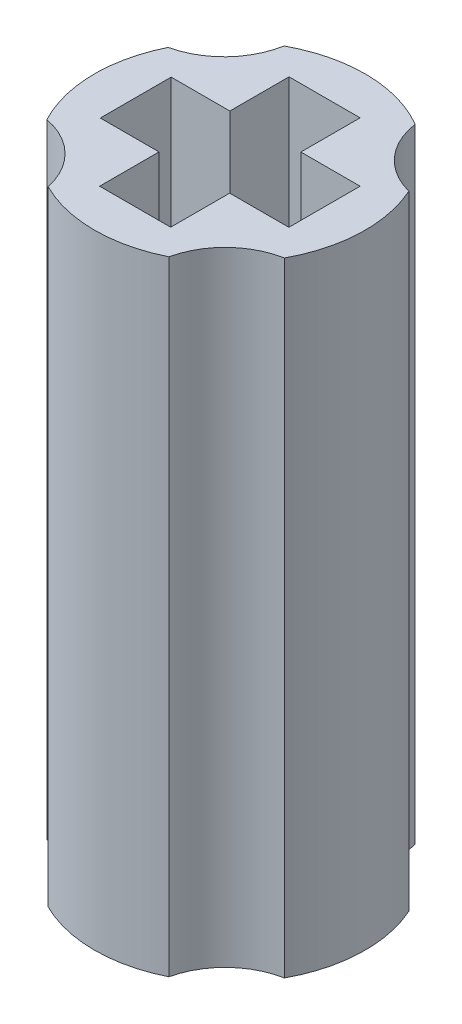
from build123d import *

# Parameters (mm, degrees)
BOSS_EXTRUDE1_DEPTH = 15.8


with BuildPart() as part:
    # Sketch1 → Boss-Extrude1 (new body)
    with BuildSketch(Plane(origin=(0, 0, 0), x_dir=(1, 0, 0), z_dir=(0, 1, 0))):
        with BuildLine():
            ThreePointArc((-3.07809394, 1.513353131), (-3.429601206, -0.052302649), (-3.030514882, -1.606511608))
            ThreePointArc((-3.030514882, -1.606511608), (-2.065248113, -2.109713097), (-1.541602156, -3.064043536))
            ThreePointArc((-1.541602156, -3.064043536), (-0.008059447, -3.429990531), (1.52718605, -3.071254266))
            ThreePointArc((1.52718605, -3.071254266), (2.055535434, -2.128465), (3.016165269, -1.633293321))
            ThreePointArc((3.016165269, -1.633293321), (3.427687897, -0.12591933), (3.127874832, 1.407586245))
            ThreePointArc((3.127874832, 1.407586245), (2.198390326, 1.972019011), (1.737882905, 2.957137637))
            ThreePointArc((1.737882905, 2.957137637), (0.056138347, 3.429540565), (-1.640166658, 3.012433125))
            ThreePointArc((-1.640166658, 3.012433125), (-2.132855627, 2.045848991), (-3.07809394, 1.513353131))
        make_face()
        Polygon((-0.9, -0.895266893), (-0.9, -2.4), (0.9, -2.4), (0.9, -0.90475813), (2.4, -0.90475813), (2.4, 0.9), (0.9, 0.9), (0.9, 2.4), (-0.9, 2.4), (-0.9, 0.9), (-2.387378381, 0.9), (-2.387378381, -0.895266893), align=None, mode=Mode.SUBTRACT)
    extrude(amount=BOSS_EXTRUDE1_DEPTH)


solid = part.part
